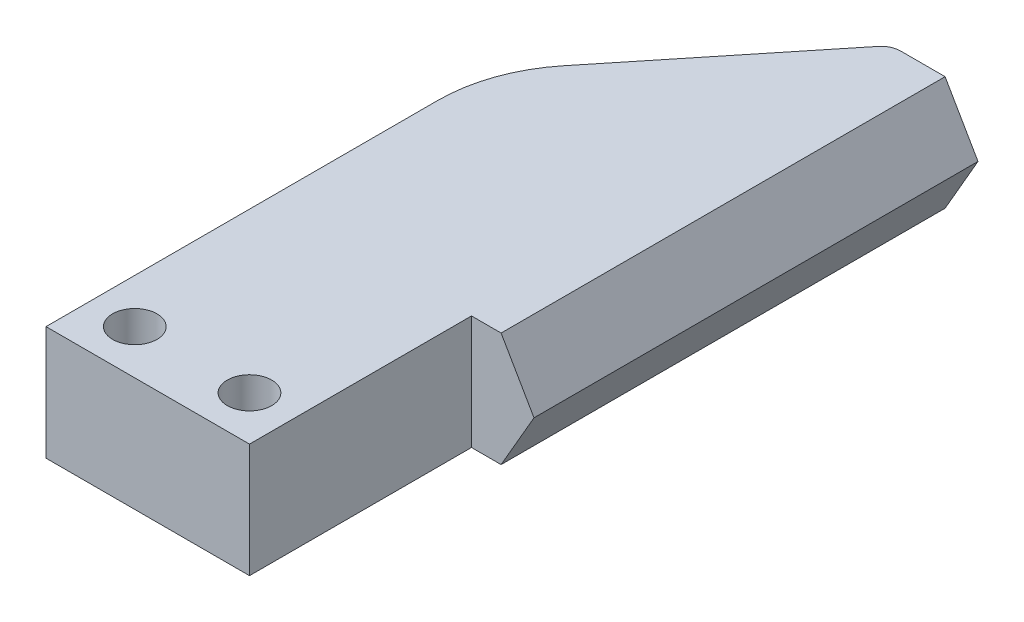
from build123d import *

# Parameters (mm, degrees)
SKETCH1_R           = 1.5
BOSS_EXTRUDE3_DEPTH = 3.85
BOSS_EXTRUDE4_DEPTH = 30


with BuildPart() as part:
    # Sketch1 → Boss-Extrude3 (new body, symmetric)
    with BuildSketch(Plane(origin=(0, 0, 0), x_dir=(1, 0, 0), z_dir=(0, 1, 0))):
        with BuildLine():
            Line((-13.75, -15), (0, -15))
            Line((0, -15), (0, 0))
            Line((0, 0), (2, 0))
            Line((2, 0), (2, 30))
            Line((2, 30), (-1, 30))
            ThreePointArc((-1, 30), (-1.576352013, 29.869367868), (-2.040057994, 29.503003078))
            Line((-2.040057994, 29.503003078), (-11.530466398, 17.748937838))
            ThreePointArc((-11.530466398, 17.748937838), (-13.178803317, 14.798188939), (-13.75, 11.466872681))
            Line((-13.75, 11.466872681), (-13.75, -15))
        make_face()
        with Locations((-10.75, -12)):
            Circle(SKETCH1_R, mode=Mode.SUBTRACT)
        with Locations((-3, -12)):
            Circle(SKETCH1_R, mode=Mode.SUBTRACT)
    extrude(amount=BOSS_EXTRUDE3_DEPTH, both=True)

    # Sketch2 → Boss-Extrude4 (add)
    with BuildSketch(Plane(origin=(0, 0, -30), x_dir=(-1, 0, 0), z_dir=(0, 0, -1))):
        Polygon((-2, 3.85), (-4.222798536, 0), (-2, -3.85), align=None)
    extrude(amount=-BOSS_EXTRUDE4_DEPTH)


solid = part.part
